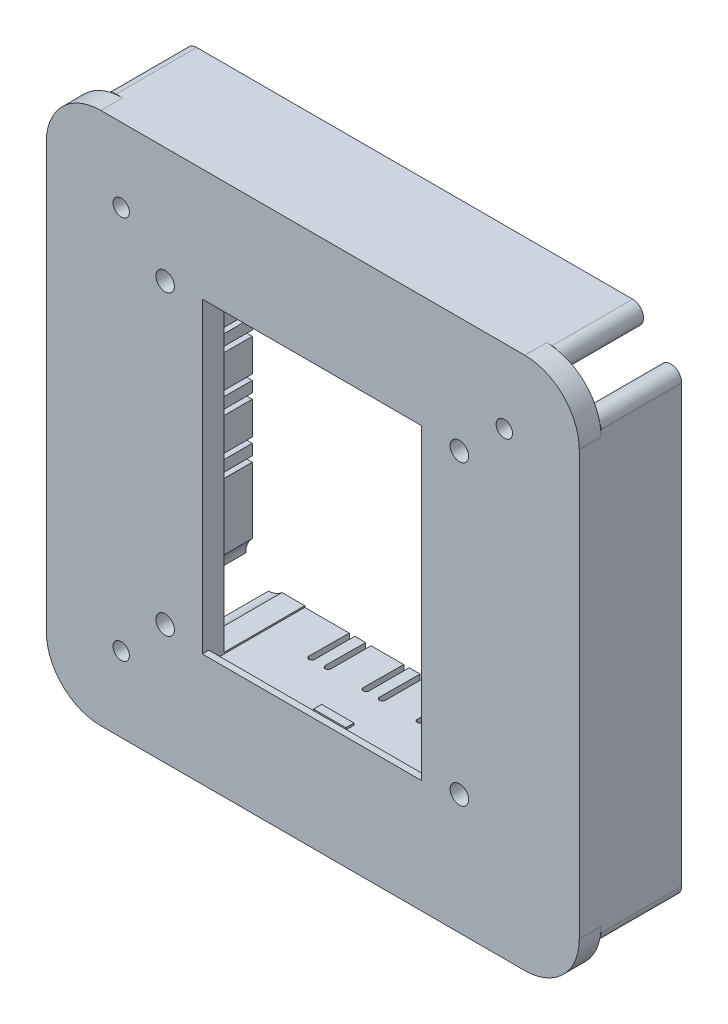
from build123d import *

# Parameters (mm, degrees)
BOSS_EXTRUDE1_DEPTH                        = 4
BOSS_EXTRUDE2_DEPTH                        = 14.8
CUT_EXTRUDE1_DEPTH                         = 21.8
CUT_EXTRUDE1_DEPTH_BACK                    = 14.8
SKETCH4_W                                  = 40.2
SKETCH4_H                                  = 60.4
SKETCH6_W                                  = 40.2
SKETCH6_H                                  = 1.2
BOSS_EXTRUDE3_DEPTH                        = 2
SKETCH7_W                                  = 40.2
SKETCH7_H                                  = 1.2
BOSS_EXTRUDE4_DEPTH                        = 2
SKETCH8_W                                  = 5.926300878
SKETCH8_H                                  = 1.5
BOSS_EXTRUDE5_DEPTH                        = 0.35
SKETCH9_R                                  = 4
CUT_EXTRUDE2_DEPTH                         = 22.15
SKETCH10_R                                 = 1.5
CUT_EXTRUDE3_DEPTH                         = 6.15
SKETCH11_R                                 = 1.7
CUT_EXTRUDE4_DEPTH                         = 60
SKETCH12_W                                 = 109.002059
SKETCH12_H                                 = 105.939191227
CUT_EXTRUDE5_DEPTH                         = 60
CUT_EXTRUDE6_DEPTH                         = 8
SKETCH13_4_R                               = 3
CUT_EXTRUDE7_DEPTH                         = 0.5
MIRROR3_COPY_1_DEPTH                       = 8
MIRROR3_COPY_2_SKETCH_R                    = 3
MIRROR3_COPY_2_DEPTH                       = 0.5
MIRROR3_COPY_3_DEPTH                       = 8
MIRROR3_COPY_4_SKETCH_R                    = 3
MIRROR3_COPY_4_DEPTH                       = 0.5
MIRROR3_AT_THE_SECOND_PLANE_COPY_1_DEPTH   = 8
MIRROR3_AT_THE_SECOND_PLANE_COPY_2_SKETC_R = 3
MIRROR3_AT_THE_SECOND_PLANE_COPY_2_DEPTH   = 0.5
MIRROR3_AT_THE_SECOND_PLANE_COPY_3_DEPTH   = 8
MIRROR3_AT_THE_SECOND_PLANE_COPY_4_SKETC_R = 3
MIRROR3_AT_THE_SECOND_PLANE_COPY_4_DEPTH   = 0.5
MIRROR3_AT_THE_SECOND_PLANE_COPY_5_DEPTH   = 8
MIRROR3_AT_THE_SECOND_PLANE_COPY_6_SKETC_R = 3
MIRROR3_AT_THE_SECOND_PLANE_COPY_6_DEPTH   = 0.5
MIRROR3_AT_THE_SECOND_PLANE_COPY_7_DEPTH   = 8
MIRROR3_AT_THE_SECOND_PLANE_COPY_8_SKETC_R = 3
MIRROR3_AT_THE_SECOND_PLANE_COPY_8_DEPTH   = 0.5
MIRROR3_AT_THE_SECOND_PLANE_COPY_9_DEPTH   = 8
MIRROR3_AT_THE_SECOND_PLANE_COPY_10_SKET_R = 3
MIRROR3_AT_THE_SECOND_PLANE_COPY_10_DEPTH  = 0.5


with BuildPart() as part:
    # Sketch1 → Boss-Extrude1 (new body)
    with BuildSketch(Plane.XY):
        with BuildLine():
            Line((-0.2, 10), (-0.2, 90))
            ThreePointArc((-0.2, 90), (-3.070353544, 96.929646456), (-10, 99.8))
            Line((-10, 99.8), (-89.8, 99.8))
            ThreePointArc((-89.8, 99.8), (-96.729646456, 96.929646456), (-99.6, 90))
            Line((-99.6, 90), (-99.6, 10))
            ThreePointArc((-99.6, 10), (-96.729646456, 3.070353544), (-89.8, 0.2))
            Line((-89.8, 0.2), (-10, 0.2))
            ThreePointArc((-10, 0.2), (-3.070353544, 3.070353544), (-0.2, 10))
        make_face()
    extrude(amount=BOSS_EXTRUDE1_DEPTH)

    # Sketch2 → Boss-Extrude2 (add)
    # profile 1 of 4: a face of its own
    with BuildSketch(Plane(origin=(0, 0, 0), x_dir=(-1, 0, 0), z_dir=(0, 0, -1))):
        with BuildLine():
            ThreePointArc((4.414213562, 91.414213562), (2.234633135, 91.847759065), (1, 90))
            Line((1, 90), (1, 10))
            ThreePointArc((1, 10), (2.234633135, 8.152240935), (4.414213562, 8.585786438))
            Line((4.414213562, 8.585786438), (19.414213562, 23.585786438))
            ThreePointArc((19.414213562, 23.585786438), (19.847759065, 24.234633135), (20, 25))
            Line((20, 25), (20, 75))
            ThreePointArc((20, 75), (19.847759065, 75.765366865), (19.414213562, 76.414213562))
            Line((19.414213562, 76.414213562), (4.414213562, 91.414213562))
        make_face()
        Polygon((3, 10), (3, 90), (18, 75), (18, 25), align=None, mode=Mode.SUBTRACT)
    # profile 2 of 4: a face of its own
    with BuildSketch(Plane(origin=(0, 0, 0), x_dir=(-1, 0, 0), z_dir=(0, 0, -1))):
        with BuildLine():
            ThreePointArc((91.414213562, 95.385786438), (91.847759065, 97.565366865), (90, 98.8))
            Line((90, 98.8), (10, 98.8))
            ThreePointArc((10, 98.8), (8.152240935, 97.565366865), (8.585786438, 95.385786438))
            Line((8.585786438, 95.385786438), (23.585786438, 80.385786438))
            ThreePointArc((23.585786438, 80.385786438), (24.234633135, 79.952240935), (25, 79.8))
            Line((25, 79.8), (75, 79.8))
            ThreePointArc((75, 79.8), (75.765366865, 79.952240935), (76.414213562, 80.385786438))
            Line((76.414213562, 80.385786438), (91.414213562, 95.385786438))
        make_face()
        Polygon((10, 96.8), (90, 96.8), (75, 81.8), (25, 81.8), align=None, mode=Mode.SUBTRACT)
    # profile 3 of 4: a face of its own
    with BuildSketch(Plane(origin=(0, 0, 0), x_dir=(-1, 0, 0), z_dir=(0, 0, -1))):
        with BuildLine():
            ThreePointArc((98.8, 90), (97.565366865, 91.847759065), (95.385786438, 91.414213562))
            Line((95.385786438, 91.414213562), (80.385786438, 76.414213562))
            ThreePointArc((80.385786438, 76.414213562), (79.952240935, 75.765366865), (79.8, 75))
            Line((79.8, 75), (79.8, 25))
            ThreePointArc((79.8, 25), (79.952240935, 24.234633135), (80.385786438, 23.585786438))
            Line((80.385786438, 23.585786438), (95.385786438, 8.585786438))
            ThreePointArc((95.385786438, 8.585786438), (97.565366865, 8.152240935), (98.8, 10))
            Line((98.8, 10), (98.8, 90))
        make_face()
        Polygon((81.8, 75), (96.8, 90), (96.8, 10), (81.8, 25), align=None, mode=Mode.SUBTRACT)
    # profile 4 of 4: a face of its own
    with BuildSketch(Plane(origin=(0, 0, 0), x_dir=(-1, 0, 0), z_dir=(0, 0, -1))):
        with BuildLine():
            ThreePointArc((90, 1), (91.847759065, 2.234633135), (91.414213562, 4.414213562))
            Line((91.414213562, 4.414213562), (76.414213562, 19.414213562))
            ThreePointArc((76.414213562, 19.414213562), (75.765366865, 19.847759065), (75, 20))
            Line((75, 20), (25, 20))
            ThreePointArc((25, 20), (24.234633135, 19.847759065), (23.585786438, 19.414213562))
            Line((23.585786438, 19.414213562), (8.585786438, 4.414213562))
            ThreePointArc((8.585786438, 4.414213562), (8.152240935, 2.234633135), (10, 1))
            Line((10, 1), (90, 1))
        make_face()
        Polygon((75, 18), (90, 3), (10, 3), (25, 18), align=None, mode=Mode.SUBTRACT)
    extrude(amount=BOSS_EXTRUDE2_DEPTH)

    # Sketch4 → Cut-Extrude1 (cut, two sides: drawn at the far end of the back side and taken through both)
    with BuildSketch(Plane(origin=(0, 0, 0), x_dir=(-1, 0, 0), z_dir=(0, 0, -1)).offset(-CUT_EXTRUDE1_DEPTH_BACK)):
        with Locations((50.070710678, 49.929289322)):
            Rectangle(SKETCH4_W, SKETCH4_H)
    extrude(amount=CUT_EXTRUDE1_DEPTH + CUT_EXTRUDE1_DEPTH_BACK, mode=Mode.SUBTRACT)

    # Sketch6 → Boss-Extrude3 (add)
    with BuildSketch(Plane.XZ.offset(-80.129289322)):
        with Locations((-50.070710678, 3.4)):
            Rectangle(SKETCH6_W, SKETCH6_H)
    extrude(amount=BOSS_EXTRUDE3_DEPTH)

    # Sketch7 → Boss-Extrude4 (add)
    with BuildSketch(Plane(origin=(0, 19.729289322, 0), x_dir=(1, 0, 0), z_dir=(0, 1, 0))):
        with Locations((-50.070710678, -3.4)):
            Rectangle(SKETCH7_W, SKETCH7_H)
    extrude(amount=BOSS_EXTRUDE4_DEPTH)

    # Sketch8 → Boss-Extrude5 (add)
    with BuildSketch(Plane(origin=(0, 19.729289322, 0), x_dir=(1, 0, 0), z_dir=(0, 1, 0))):
        with Locations((-49.9, -0.15)):
            Rectangle(SKETCH8_W, SKETCH8_H)
    extrude(amount=BOSS_EXTRUDE5_DEPTH)

    # Sketch9 → Cut-Extrude2 (cut)
    with BuildSketch(Plane(origin=(0, 0, 0), x_dir=(-1, 0, 0), z_dir=(0, 0, -1))):
        with Locations((23, 77.572807955)):
            Circle(SKETCH9_R)
        with Locations((23, 23)):
            Circle(SKETCH9_R)
        with Locations((77, 23)):
            Circle(SKETCH9_R)
        with Locations((77, 77.572807955)):
            Circle(SKETCH9_R)
    extrude(amount=CUT_EXTRUDE2_DEPTH, mode=Mode.SUBTRACT)

    # Sketch10 → Cut-Extrude3 (cut)
    with BuildSketch(Plane.XY.offset(4)):
        with Locations((-85.055107735, 85.230177932)):
            Circle(SKETCH10_R)
        with Locations((-85.055107735, 14.769822068)):
            Circle(SKETCH10_R)
        with Locations((-14.744892265, 85.230177932)):
            Circle(SKETCH10_R)
    extrude(amount=-CUT_EXTRUDE3_DEPTH, mode=Mode.SUBTRACT)

    # Sketch11 → Cut-Extrude4 (cut)
    with BuildSketch(Plane(origin=(0, 0, 0), x_dir=(-1, 0, 0), z_dir=(0, 0, -1))):
        with Locations((77, 77.572807955)):
            Circle(SKETCH11_R)
        with Locations((77, 23)):
            Circle(SKETCH11_R)
        with Locations((23, 23)):
            Circle(SKETCH11_R)
        with Locations((23, 77.572807955)):
            Circle(SKETCH11_R)
    extrude(amount=-CUT_EXTRUDE4_DEPTH, mode=Mode.SUBTRACT)

    # Sketch12 → Cut-Extrude5 (cut)
    with BuildSketch(Plane(origin=(0, 0, 0), x_dir=(-1, 0, 0), z_dir=(0, 0, -1))):
        with Locations((50.530689711, 49.932615209)):
            Rectangle(SKETCH12_W, SKETCH12_H)
        with BuildLine():
            Line((11, 98.8), (88.8, 98.8))
            ThreePointArc((88.8, 98.8), (95.871067812, 95.871067812), (98.8, 88.8))
            Line((98.8, 88.8), (98.8, 11))
            ThreePointArc((98.8, 11), (95.871067812, 3.928932188), (88.8, 1))
            Line((88.8, 1), (11, 1))
            ThreePointArc((11, 1), (3.928932188, 3.928932188), (1, 11))
            Line((1, 11), (1, 88.8))
            ThreePointArc((1, 88.8), (3.928932188, 95.871067812), (11, 98.8))
        make_face(mode=Mode.SUBTRACT)
    extrude(amount=-CUT_EXTRUDE5_DEPTH, mode=Mode.SUBTRACT)

    # Sketch13 → Cut-Extrude6 (cut)
    with BuildSketch(Plane(origin=(-18, 0, 0), x_dir=(0, 0, -1), z_dir=(1, 0, 0))):
        with BuildLine():
            ThreePointArc((7.4, 52), (6.9, 51.5), (7.4, 51))
            Line((7.4, 51), (14.8, 51))
            Line((14.8, 51), (14.8, 52))
            Line((14.8, 52), (7.4, 52))
        make_face()
        with BuildLine():
            Line((14.8, 41), (14.8, 42))
            Line((14.8, 42), (7.4, 42))
            ThreePointArc((7.4, 42), (6.9, 41.5), (7.4, 41))
            Line((7.4, 41), (14.8, 41))
        make_face()
        with BuildLine():
            Line((14.8, 58), (14.8, 59))
            Line((14.8, 59), (7.4, 59))
            ThreePointArc((7.4, 59), (6.9, 58.5), (7.4, 58))
            Line((7.4, 58), (14.8, 58))
        make_face()
        with BuildLine():
            Line((14.8, 48), (14.8, 49))
            Line((14.8, 49), (7.4, 49))
            ThreePointArc((7.4, 49), (6.9, 48.5), (7.4, 48))
            Line((7.4, 48), (14.8, 48))
        make_face()
        with BuildLine():
            Line((7.4, 61), (14.8, 61))
            Line((14.8, 61), (14.8, 62))
            Line((14.8, 62), (7.4, 62))
            ThreePointArc((7.4, 62), (6.9, 61.5), (7.4, 61))
        make_face()
        with BuildLine():
            Line((14.8, 38), (14.8, 39))
            Line((14.8, 39), (7.4, 39))
            ThreePointArc((7.4, 39), (6.9, 38.5), (7.4, 38))
            Line((7.4, 38), (14.8, 38))
        make_face()
    cut_extrude6 = extrude(amount=-CUT_EXTRUDE6_DEPTH, mode=Mode.SUBTRACT)

    # Sketch13_4 → Cut-Extrude7 (cut)
    with BuildSketch(Plane(origin=(-18, 0, 0), x_dir=(0, 0, -1), z_dir=(1, 0, 0))):
        with BuildLine():
            Line((10.228427125, 51), (7.4, 51))
            ThreePointArc((7.4, 51), (6.9, 51.5), (7.4, 52))
            Line((7.4, 52), (9.636067977, 52))
            ThreePointArc((9.636067977, 52), (4.4, 50), (9.636067977, 48))
            Line((9.636067977, 48), (7.4, 48))
            ThreePointArc((7.4, 48), (6.9, 48.5), (7.4, 49))
            Line((7.4, 49), (10.228427125, 49))
            ThreePointArc((10.228427125, 49), (10.4, 50), (10.228427125, 51))
        make_face()
        with Locations((7.4, 60)):
            Circle(SKETCH13_4_R)
        with Locations((7.4, 40)):
            Circle(SKETCH13_4_R)
    cut_extrude7 = extrude(amount=-CUT_EXTRUDE7_DEPTH, mode=Mode.SUBTRACT)

    # Mirror2: Cut-Extrude6, Cut-Extrude7 across plane
    add(cut_extrude6.mirror(Plane(origin=(0, 0, 0), x_dir=(0, 0, 1), z_dir=(-0.7071067811865475, -0.7071067811865476, 0))), mode=Mode.SUBTRACT)
    add(cut_extrude7.mirror(Plane(origin=(0, 0, 0), x_dir=(0, 0, 1), z_dir=(-0.7071067811865475, -0.7071067811865476, 0))), mode=Mode.SUBTRACT)

    # Mirror3 copy 1 sketch → Mirror3 copy 1 (cut)
    with BuildSketch(Plane(origin=(-100.117306458, 18, -0.402236513), x_dir=(0.00803517463167391, 0, -0.9999677174632382), z_dir=(0, -1, 0))):
        with BuildLine():
            ThreePointArc((7.4, 52), (6.9, 51.5), (7.4, 51))
            Line((7.4, 51), (14.8, 51))
            Line((14.8, 51), (14.8, 52))
            Line((14.8, 52), (7.4, 52))
        make_face()
        with BuildLine():
            Line((14.8, 41), (14.8, 42))
            Line((14.8, 42), (7.4, 42))
            ThreePointArc((7.4, 42), (6.9, 41.5), (7.4, 41))
            Line((7.4, 41), (14.8, 41))
        make_face()
        with BuildLine():
            Line((14.8, 58), (14.8, 59))
            Line((14.8, 59), (7.4, 59))
            ThreePointArc((7.4, 59), (6.9, 58.5), (7.4, 58))
            Line((7.4, 58), (14.8, 58))
        make_face()
        with BuildLine():
            Line((14.8, 48), (14.8, 49))
            Line((14.8, 49), (7.4, 49))
            ThreePointArc((7.4, 49), (6.9, 48.5), (7.4, 48))
            Line((7.4, 48), (14.8, 48))
        make_face()
        with BuildLine():
            Line((7.4, 61), (14.8, 61))
            Line((14.8, 61), (14.8, 62))
            Line((14.8, 62), (7.4, 62))
            ThreePointArc((7.4, 62), (6.9, 61.5), (7.4, 61))
        make_face()
        with BuildLine():
            Line((14.8, 38), (14.8, 39))
            Line((14.8, 39), (7.4, 39))
            ThreePointArc((7.4, 39), (6.9, 38.5), (7.4, 38))
            Line((7.4, 38), (14.8, 38))
        make_face()
    extrude(amount=-MIRROR3_COPY_1_DEPTH, mode=Mode.SUBTRACT)

    # Mirror3 copy 2 sketch → Mirror3 copy 2 (cut)
    with BuildSketch(Plane(origin=(-100.117306458, 18, -0.402236513), x_dir=(0.00803517463167391, 0, -0.9999677174632382), z_dir=(0, -1, 0))):
        with BuildLine():
            Line((10.228427125, 51), (7.4, 51))
            ThreePointArc((7.4, 51), (6.9, 51.5), (7.4, 52))
            Line((7.4, 52), (9.636067977, 52))
            ThreePointArc((9.636067977, 52), (4.4, 50), (9.636067977, 48))
            Line((9.636067977, 48), (7.4, 48))
            ThreePointArc((7.4, 48), (6.9, 48.5), (7.4, 49))
            Line((7.4, 49), (10.228427125, 49))
            ThreePointArc((10.228427125, 49), (10.4, 50), (10.228427125, 51))
        make_face()
        with Locations((7.4, 60)):
            Circle(MIRROR3_COPY_2_SKETCH_R)
        with Locations((7.4, 40)):
            Circle(MIRROR3_COPY_2_SKETCH_R)
    extrude(amount=-MIRROR3_COPY_2_DEPTH, mode=Mode.SUBTRACT)

    # Mirror3 copy 3 sketch → Mirror3 copy 3 (cut)
    with BuildSketch(Plane(origin=(-82.117887543, 0, -0.25760337), x_dir=(0.00803517463167391, 0, -0.9999677174632382), z_dir=(-0.9999677174632384, 4.7371475684700095e-15, -0.00803517463167391))):
        with BuildLine():
            ThreePointArc((7.4, -52), (6.9, -51.5), (7.4, -51))
            Line((7.4, -51), (14.8, -51))
            Line((14.8, -51), (14.8, -52))
            Line((14.8, -52), (7.4, -52))
        make_face()
        with BuildLine():
            Line((14.8, -41), (14.8, -42))
            Line((14.8, -42), (7.4, -42))
            ThreePointArc((7.4, -42), (6.9, -41.5), (7.4, -41))
            Line((7.4, -41), (14.8, -41))
        make_face()
        with BuildLine():
            Line((14.8, -58), (14.8, -59))
            Line((14.8, -59), (7.4, -59))
            ThreePointArc((7.4, -59), (6.9, -58.5), (7.4, -58))
            Line((7.4, -58), (14.8, -58))
        make_face()
        with BuildLine():
            Line((14.8, -48), (14.8, -49))
            Line((14.8, -49), (7.4, -49))
            ThreePointArc((7.4, -49), (6.9, -48.5), (7.4, -48))
            Line((7.4, -48), (14.8, -48))
        make_face()
        with BuildLine():
            Line((7.4, -61), (14.8, -61))
            Line((14.8, -61), (14.8, -62))
            Line((14.8, -62), (7.4, -62))
            ThreePointArc((7.4, -62), (6.9, -61.5), (7.4, -61))
        make_face()
        with BuildLine():
            Line((14.8, -38), (14.8, -39))
            Line((14.8, -39), (7.4, -39))
            ThreePointArc((7.4, -39), (6.9, -38.5), (7.4, -38))
            Line((7.4, -38), (14.8, -38))
        make_face()
    extrude(amount=-MIRROR3_COPY_3_DEPTH, mode=Mode.SUBTRACT)

    # Mirror3 copy 4 sketch → Mirror3 copy 4 (cut)
    with BuildSketch(Plane(origin=(-82.117887543, 0, -0.25760337), x_dir=(0.00803517463167391, 0, -0.9999677174632382), z_dir=(-0.9999677174632384, 4.7371475684700095e-15, -0.00803517463167391))):
        with BuildLine():
            Line((10.228427125, -51), (7.4, -51))
            ThreePointArc((7.4, -51), (6.9, -51.5), (7.4, -52))
            Line((7.4, -52), (9.636067977, -52))
            ThreePointArc((9.636067977, -52), (4.4, -50), (9.636067977, -48))
            Line((9.636067977, -48), (7.4, -48))
            ThreePointArc((7.4, -48), (6.9, -48.5), (7.4, -49))
            Line((7.4, -49), (10.228427125, -49))
            ThreePointArc((10.228427125, -49), (10.4, -50), (10.228427125, -51))
        make_face()
        with Locations((7.4, -60)):
            Circle(MIRROR3_COPY_4_SKETCH_R)
        with Locations((7.4, -40)):
            Circle(MIRROR3_COPY_4_SKETCH_R)
    extrude(amount=-MIRROR3_COPY_4_DEPTH, mode=Mode.SUBTRACT)

    # Mirror3 at the second plane copy 1 sketc → Mirror3 at the second plane copy 1 (cut)
    with BuildSketch(Plane(origin=(0, 82, 0), x_dir=(0, 0, -1), z_dir=(0, 1, 0))):
        with BuildLine():
            ThreePointArc((7.4, 52), (6.9, 51.5), (7.4, 51))
            Line((7.4, 51), (14.8, 51))
            Line((14.8, 51), (14.8, 52))
            Line((14.8, 52), (7.4, 52))
        make_face()
        with BuildLine():
            Line((14.8, 41), (14.8, 42))
            Line((14.8, 42), (7.4, 42))
            ThreePointArc((7.4, 42), (6.9, 41.5), (7.4, 41))
            Line((7.4, 41), (14.8, 41))
        make_face()
        with BuildLine():
            Line((14.8, 58), (14.8, 59))
            Line((14.8, 59), (7.4, 59))
            ThreePointArc((7.4, 59), (6.9, 58.5), (7.4, 58))
            Line((7.4, 58), (14.8, 58))
        make_face()
        with BuildLine():
            Line((14.8, 48), (14.8, 49))
            Line((14.8, 49), (7.4, 49))
            ThreePointArc((7.4, 49), (6.9, 48.5), (7.4, 48))
            Line((7.4, 48), (14.8, 48))
        make_face()
        with BuildLine():
            Line((7.4, 61), (14.8, 61))
            Line((14.8, 61), (14.8, 62))
            Line((14.8, 62), (7.4, 62))
            ThreePointArc((7.4, 62), (6.9, 61.5), (7.4, 61))
        make_face()
        with BuildLine():
            Line((14.8, 38), (14.8, 39))
            Line((14.8, 39), (7.4, 39))
            ThreePointArc((7.4, 39), (6.9, 38.5), (7.4, 38))
            Line((7.4, 38), (14.8, 38))
        make_face()
    extrude(amount=-MIRROR3_AT_THE_SECOND_PLANE_COPY_1_DEPTH, mode=Mode.SUBTRACT)

    # Mirror3 at the second plane copy 2 sketc → Mirror3 at the second plane copy 2 (cut)
    with BuildSketch(Plane(origin=(0, 82, 0), x_dir=(0, 0, -1), z_dir=(0, 1, 0))):
        with BuildLine():
            Line((10.228427125, 51), (7.4, 51))
            ThreePointArc((7.4, 51), (6.9, 51.5), (7.4, 52))
            Line((7.4, 52), (9.636067977, 52))
            ThreePointArc((9.636067977, 52), (4.4, 50), (9.636067977, 48))
            Line((9.636067977, 48), (7.4, 48))
            ThreePointArc((7.4, 48), (6.9, 48.5), (7.4, 49))
            Line((7.4, 49), (10.228427125, 49))
            ThreePointArc((10.228427125, 49), (10.4, 50), (10.228427125, 51))
        make_face()
        with Locations((7.4, 60)):
            Circle(MIRROR3_AT_THE_SECOND_PLANE_COPY_2_SKETC_R)
        with Locations((7.4, 40)):
            Circle(MIRROR3_AT_THE_SECOND_PLANE_COPY_2_SKETC_R)
    extrude(amount=-MIRROR3_AT_THE_SECOND_PLANE_COPY_2_DEPTH, mode=Mode.SUBTRACT)

    # Mirror3 at the second plane copy 3 sketc → Mirror3 at the second plane copy 3 (cut)
    with BuildSketch(Plane(origin=(-18, 100, 0), x_dir=(0, 0, -1), z_dir=(1, 0, 0))):
        with BuildLine():
            ThreePointArc((7.4, -52), (6.9, -51.5), (7.4, -51))
            Line((7.4, -51), (14.8, -51))
            Line((14.8, -51), (14.8, -52))
            Line((14.8, -52), (7.4, -52))
        make_face()
        with BuildLine():
            Line((14.8, -41), (14.8, -42))
            Line((14.8, -42), (7.4, -42))
            ThreePointArc((7.4, -42), (6.9, -41.5), (7.4, -41))
            Line((7.4, -41), (14.8, -41))
        make_face()
        with BuildLine():
            Line((14.8, -58), (14.8, -59))
            Line((14.8, -59), (7.4, -59))
            ThreePointArc((7.4, -59), (6.9, -58.5), (7.4, -58))
            Line((7.4, -58), (14.8, -58))
        make_face()
        with BuildLine():
            Line((14.8, -48), (14.8, -49))
            Line((14.8, -49), (7.4, -49))
            ThreePointArc((7.4, -49), (6.9, -48.5), (7.4, -48))
            Line((7.4, -48), (14.8, -48))
        make_face()
        with BuildLine():
            Line((7.4, -61), (14.8, -61))
            Line((14.8, -61), (14.8, -62))
            Line((14.8, -62), (7.4, -62))
            ThreePointArc((7.4, -62), (6.9, -61.5), (7.4, -61))
        make_face()
        with BuildLine():
            Line((14.8, -38), (14.8, -39))
            Line((14.8, -39), (7.4, -39))
            ThreePointArc((7.4, -39), (6.9, -38.5), (7.4, -38))
            Line((7.4, -38), (14.8, -38))
        make_face()
    extrude(amount=-MIRROR3_AT_THE_SECOND_PLANE_COPY_3_DEPTH, mode=Mode.SUBTRACT)

    # Mirror3 at the second plane copy 4 sketc → Mirror3 at the second plane copy 4 (cut)
    with BuildSketch(Plane(origin=(-18, 100, 0), x_dir=(0, 0, -1), z_dir=(1, 0, 0))):
        with BuildLine():
            Line((10.228427125, -51), (7.4, -51))
            ThreePointArc((7.4, -51), (6.9, -51.5), (7.4, -52))
            Line((7.4, -52), (9.636067977, -52))
            ThreePointArc((9.636067977, -52), (4.4, -50), (9.636067977, -48))
            Line((9.636067977, -48), (7.4, -48))
            ThreePointArc((7.4, -48), (6.9, -48.5), (7.4, -49))
            Line((7.4, -49), (10.228427125, -49))
            ThreePointArc((10.228427125, -49), (10.4, -50), (10.228427125, -51))
        make_face()
        with Locations((7.4, -60)):
            Circle(MIRROR3_AT_THE_SECOND_PLANE_COPY_4_SKETC_R)
        with Locations((7.4, -40)):
            Circle(MIRROR3_AT_THE_SECOND_PLANE_COPY_4_SKETC_R)
    extrude(amount=-MIRROR3_AT_THE_SECOND_PLANE_COPY_4_DEPTH, mode=Mode.SUBTRACT)

    # Mirror3 at the second plane copy 5 sketc → Mirror3 at the second plane copy 5 (cut)
    with BuildSketch(Plane(origin=(-100.117306458, 82, -0.402236513), x_dir=(0.00803517463167391, -1.8688163581169225e-15, -0.9999677174632382), z_dir=(0, 1, 0))):
        with BuildLine():
            ThreePointArc((7.4, -52), (6.9, -51.5), (7.4, -51))
            Line((7.4, -51), (14.8, -51))
            Line((14.8, -51), (14.8, -52))
            Line((14.8, -52), (7.4, -52))
        make_face()
        with BuildLine():
            Line((14.8, -41), (14.8, -42))
            Line((14.8, -42), (7.4, -42))
            ThreePointArc((7.4, -42), (6.9, -41.5), (7.4, -41))
            Line((7.4, -41), (14.8, -41))
        make_face()
        with BuildLine():
            Line((14.8, -58), (14.8, -59))
            Line((14.8, -59), (7.4, -59))
            ThreePointArc((7.4, -59), (6.9, -58.5), (7.4, -58))
            Line((7.4, -58), (14.8, -58))
        make_face()
        with BuildLine():
            Line((14.8, -48), (14.8, -49))
            Line((14.8, -49), (7.4, -49))
            ThreePointArc((7.4, -49), (6.9, -48.5), (7.4, -48))
            Line((7.4, -48), (14.8, -48))
        make_face()
        with BuildLine():
            Line((7.4, -61), (14.8, -61))
            Line((14.8, -61), (14.8, -62))
            Line((14.8, -62), (7.4, -62))
            ThreePointArc((7.4, -62), (6.9, -61.5), (7.4, -61))
        make_face()
        with BuildLine():
            Line((14.8, -38), (14.8, -39))
            Line((14.8, -39), (7.4, -39))
            ThreePointArc((7.4, -39), (6.9, -38.5), (7.4, -38))
            Line((7.4, -38), (14.8, -38))
        make_face()
    extrude(amount=-MIRROR3_AT_THE_SECOND_PLANE_COPY_5_DEPTH, mode=Mode.SUBTRACT)

    # Mirror3 at the second plane copy 6 sketc → Mirror3 at the second plane copy 6 (cut)
    with BuildSketch(Plane(origin=(-100.117306458, 82, -0.402236513), x_dir=(0.00803517463167391, -1.8688163581169225e-15, -0.9999677174632382), z_dir=(0, 1, 0))):
        with BuildLine():
            Line((10.228427125, -51), (7.4, -51))
            ThreePointArc((7.4, -51), (6.9, -51.5), (7.4, -52))
            Line((7.4, -52), (9.636067977, -52))
            ThreePointArc((9.636067977, -52), (4.4, -50), (9.636067977, -48))
            Line((9.636067977, -48), (7.4, -48))
            ThreePointArc((7.4, -48), (6.9, -48.5), (7.4, -49))
            Line((7.4, -49), (10.228427125, -49))
            ThreePointArc((10.228427125, -49), (10.4, -50), (10.228427125, -51))
        make_face()
        with Locations((7.4, -60)):
            Circle(MIRROR3_AT_THE_SECOND_PLANE_COPY_6_SKETC_R)
        with Locations((7.4, -40)):
            Circle(MIRROR3_AT_THE_SECOND_PLANE_COPY_6_SKETC_R)
    extrude(amount=-MIRROR3_AT_THE_SECOND_PLANE_COPY_6_DEPTH, mode=Mode.SUBTRACT)

    # Mirror3 at the second plane copy 7 sketc → Mirror3 at the second plane copy 7 (cut)
    with BuildSketch(Plane(origin=(-82.117887543, 100, -0.25760337), x_dir=(0.00803517463167391, -1.8688163581169225e-15, -0.9999677174632382), z_dir=(-0.9999677174632384, -4.309622474511204e-15, -0.00803517463167391))):
        with BuildLine():
            ThreePointArc((7.4, 52), (6.9, 51.5), (7.4, 51))
            Line((7.4, 51), (14.8, 51))
            Line((14.8, 51), (14.8, 52))
            Line((14.8, 52), (7.4, 52))
        make_face()
        with BuildLine():
            Line((14.8, 41), (14.8, 42))
            Line((14.8, 42), (7.4, 42))
            ThreePointArc((7.4, 42), (6.9, 41.5), (7.4, 41))
            Line((7.4, 41), (14.8, 41))
        make_face()
        with BuildLine():
            Line((14.8, 58), (14.8, 59))
            Line((14.8, 59), (7.4, 59))
            ThreePointArc((7.4, 59), (6.9, 58.5), (7.4, 58))
            Line((7.4, 58), (14.8, 58))
        make_face()
        with BuildLine():
            Line((14.8, 48), (14.8, 49))
            Line((14.8, 49), (7.4, 49))
            ThreePointArc((7.4, 49), (6.9, 48.5), (7.4, 48))
            Line((7.4, 48), (14.8, 48))
        make_face()
        with BuildLine():
            Line((7.4, 61), (14.8, 61))
            Line((14.8, 61), (14.8, 62))
            Line((14.8, 62), (7.4, 62))
            ThreePointArc((7.4, 62), (6.9, 61.5), (7.4, 61))
        make_face()
        with BuildLine():
            Line((14.8, 38), (14.8, 39))
            Line((14.8, 39), (7.4, 39))
            ThreePointArc((7.4, 39), (6.9, 38.5), (7.4, 38))
            Line((7.4, 38), (14.8, 38))
        make_face()
    extrude(amount=-MIRROR3_AT_THE_SECOND_PLANE_COPY_7_DEPTH, mode=Mode.SUBTRACT)

    # Mirror3 at the second plane copy 8 sketc → Mirror3 at the second plane copy 8 (cut)
    with BuildSketch(Plane(origin=(-82.117887543, 100, -0.25760337), x_dir=(0.00803517463167391, -1.8688163581169225e-15, -0.9999677174632382), z_dir=(-0.9999677174632384, -4.309622474511204e-15, -0.00803517463167391))):
        with BuildLine():
            Line((10.228427125, 51), (7.4, 51))
            ThreePointArc((7.4, 51), (6.9, 51.5), (7.4, 52))
            Line((7.4, 52), (9.636067977, 52))
            ThreePointArc((9.636067977, 52), (4.4, 50), (9.636067977, 48))
            Line((9.636067977, 48), (7.4, 48))
            ThreePointArc((7.4, 48), (6.9, 48.5), (7.4, 49))
            Line((7.4, 49), (10.228427125, 49))
            ThreePointArc((10.228427125, 49), (10.4, 50), (10.228427125, 51))
        make_face()
        with Locations((7.4, 60)):
            Circle(MIRROR3_AT_THE_SECOND_PLANE_COPY_8_SKETC_R)
        with Locations((7.4, 40)):
            Circle(MIRROR3_AT_THE_SECOND_PLANE_COPY_8_SKETC_R)
    extrude(amount=-MIRROR3_AT_THE_SECOND_PLANE_COPY_8_DEPTH, mode=Mode.SUBTRACT)

    # Mirror3 at the second plane copy 9 sketc → Mirror3 at the second plane copy 9 (cut)
    with BuildSketch(Plane(origin=(-18, 100, 0), x_dir=(0, 0, -1), z_dir=(1, 0, 0))):
        with BuildLine():
            ThreePointArc((7.4, -52), (6.9, -51.5), (7.4, -51))
            Line((7.4, -51), (14.8, -51))
            Line((14.8, -51), (14.8, -52))
            Line((14.8, -52), (7.4, -52))
        make_face()
        with BuildLine():
            Line((14.8, -41), (14.8, -42))
            Line((14.8, -42), (7.4, -42))
            ThreePointArc((7.4, -42), (6.9, -41.5), (7.4, -41))
            Line((7.4, -41), (14.8, -41))
        make_face()
        with BuildLine():
            Line((14.8, -58), (14.8, -59))
            Line((14.8, -59), (7.4, -59))
            ThreePointArc((7.4, -59), (6.9, -58.5), (7.4, -58))
            Line((7.4, -58), (14.8, -58))
        make_face()
        with BuildLine():
            Line((14.8, -48), (14.8, -49))
            Line((14.8, -49), (7.4, -49))
            ThreePointArc((7.4, -49), (6.9, -48.5), (7.4, -48))
            Line((7.4, -48), (14.8, -48))
        make_face()
        with BuildLine():
            Line((7.4, -61), (14.8, -61))
            Line((14.8, -61), (14.8, -62))
            Line((14.8, -62), (7.4, -62))
            ThreePointArc((7.4, -62), (6.9, -61.5), (7.4, -61))
        make_face()
        with BuildLine():
            Line((14.8, -38), (14.8, -39))
            Line((14.8, -39), (7.4, -39))
            ThreePointArc((7.4, -39), (6.9, -38.5), (7.4, -38))
            Line((7.4, -38), (14.8, -38))
        make_face()
    extrude(amount=-MIRROR3_AT_THE_SECOND_PLANE_COPY_9_DEPTH, mode=Mode.SUBTRACT)

    # Mirror3 at the second plane copy 10 sket → Mirror3 at the second plane copy 10 (cut)
    with BuildSketch(Plane(origin=(-18, 100, 0), x_dir=(0, 0, -1), z_dir=(1, 0, 0))):
        with BuildLine():
            Line((10.228427125, -51), (7.4, -51))
            ThreePointArc((7.4, -51), (6.9, -51.5), (7.4, -52))
            Line((7.4, -52), (9.636067977, -52))
            ThreePointArc((9.636067977, -52), (4.4, -50), (9.636067977, -48))
            Line((9.636067977, -48), (7.4, -48))
            ThreePointArc((7.4, -48), (6.9, -48.5), (7.4, -49))
            Line((7.4, -49), (10.228427125, -49))
            ThreePointArc((10.228427125, -49), (10.4, -50), (10.228427125, -51))
        make_face()
        with Locations((7.4, -60)):
            Circle(MIRROR3_AT_THE_SECOND_PLANE_COPY_10_SKET_R)
        with Locations((7.4, -40)):
            Circle(MIRROR3_AT_THE_SECOND_PLANE_COPY_10_SKET_R)
    extrude(amount=-MIRROR3_AT_THE_SECOND_PLANE_COPY_10_DEPTH, mode=Mode.SUBTRACT)


solid = part.part
